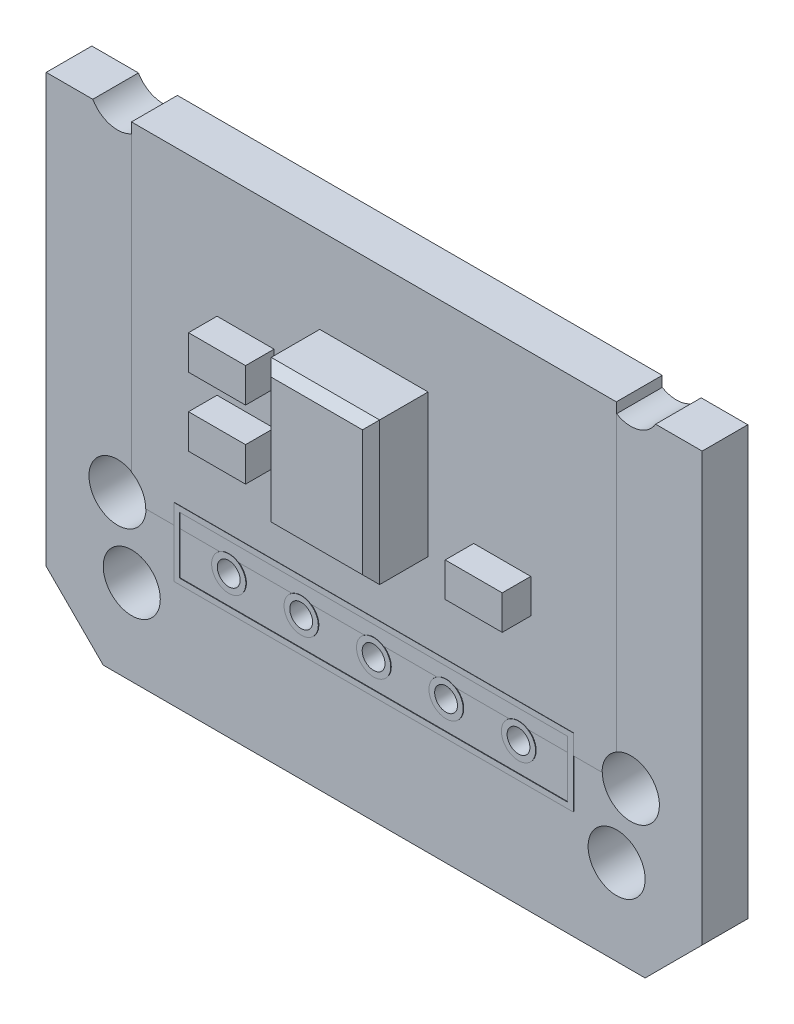
from build123d import *

# Parameters (mm, degrees)
SKETCH1_R           = 1
BOSS_EXTRUDE1_DEPTH = 1.6
SKETCH2_W           = 17
SKETCH2_H           = 12
BOSS_EXTRUDE2_DEPTH = 1.61
SKETCH3_W           = 14
SKETCH3_H           = 2.4
SKETCH3_W_2         = 13.6
SKETCH3_H_2         = 2
SKETCH3_R           = 0.6
SKETCH3_R_2         = 0.4
BOSS_EXTRUDE3_DEPTH = 1.62
SKETCH3_3_R         = 0.4
CUT_EXTRUDE1_DEPTH  = 2.62
BOSS_EXTRUDE4_START = 1.61
SKETCH4_W           = 3.8
SKETCH4_H           = 5
BOSS_EXTRUDE4_DEPTH = 2
BOSS_EXTRUDE5_START = 1.61
SKETCH5_W           = 2
SKETCH5_H           = 1.2
BOSS_EXTRUDE5_DEPTH = 1
CHAMFER1_SIZE       = 0.3
SKETCH6_R           = 1
SKETCH6_W           = 23
SKETCH6_H           = 6
CUT_EXTRUDE2_DEPTH  = 2


with BuildPart() as part:
    # Sketch1 → Boss-Extrude1 (new body)
    with BuildSketch(Plane.XY):
        Polygon((-11.5, 9.5), (-9.5, 11.5), (9.5, 11.5), (11.5, 9.5), (11.5, -9.5), (9.5, -11.5), (-9.5, -11.5), (-11.5, -9.5), align=None)
        with Locations((-9, 6)):
            Circle(SKETCH1_R, mode=Mode.SUBTRACT)
        with Locations((9, 6)):
            Circle(SKETCH1_R, mode=Mode.SUBTRACT)
        with Locations((-9, -6)):
            Circle(SKETCH1_R, mode=Mode.SUBTRACT)
        with Locations((9, -6)):
            Circle(SKETCH1_R, mode=Mode.SUBTRACT)
        with Locations((8.5, -8.5)):
            Circle(SKETCH1_R, mode=Mode.SUBTRACT)
        with Locations((-8.5, -8.5)):
            Circle(SKETCH1_R, mode=Mode.SUBTRACT)
    extrude(amount=BOSS_EXTRUDE1_DEPTH)

    # Sketch2 → Boss-Extrude2 (add)
    with BuildSketch(Plane.XY):
        Rectangle(SKETCH2_W, SKETCH2_H)
    extrude(amount=BOSS_EXTRUDE2_DEPTH)

    # Sketch3 → Boss-Extrude3 (add)
    with BuildSketch(Plane.XY):
        with Locations((0, -6.5)):
            Rectangle(SKETCH3_W, SKETCH3_H)
        with Locations((0, -6.5)):
            Rectangle(SKETCH3_W_2, SKETCH3_H_2, mode=Mode.SUBTRACT)
        with Locations(Location((-5.08, -6.5, 0), (0, 0, 123.557309762))):
            Circle(SKETCH3_R)
        with Locations((-5.08, -6.5)):
            Circle(SKETCH3_R_2, mode=Mode.SUBTRACT)
        with Locations(Location((-2.54, -6.5, 0), (0, 0, 123.557309762))):
            Circle(SKETCH3_R)
        with Locations((-2.54, -6.5)):
            Circle(SKETCH3_R_2, mode=Mode.SUBTRACT)
        with Locations(Location((0, -6.5, 0), (0, 0, 123.557309762))):
            Circle(SKETCH3_R)
        with Locations((0, -6.5)):
            Circle(SKETCH3_R_2, mode=Mode.SUBTRACT)
        with Locations(Location((5.08, -6.5, 0), (0, 0, 123.557309762))):
            Circle(SKETCH3_R)
        with Locations((5.08, -6.5)):
            Circle(SKETCH3_R_2, mode=Mode.SUBTRACT)
        with Locations(Location((2.54, -6.5, 0), (0, 0, 123.557309762))):
            Circle(SKETCH3_R)
        with Locations((2.54, -6.5)):
            Circle(SKETCH3_R_2, mode=Mode.SUBTRACT)
    extrude(amount=BOSS_EXTRUDE3_DEPTH)

    # Sketch3_3 → Cut-Extrude1 (cut)
    with BuildSketch(Plane.XY):
        with Locations((-5.08, -6.5)):
            Circle(SKETCH3_3_R)
        with Locations((-2.54, -6.5)):
            Circle(SKETCH3_3_R)
        with Locations((0, -6.5)):
            Circle(SKETCH3_3_R)
        with Locations((2.54, -6.5)):
            Circle(SKETCH3_3_R)
        with Locations((5.08, -6.5)):
            Circle(SKETCH3_3_R)
    extrude(amount=CUT_EXTRUDE1_DEPTH, mode=Mode.SUBTRACT)

    # Sketch4 → Boss-Extrude4 (add)
    with BuildSketch(Plane.XY.offset(BOSS_EXTRUDE4_START)):
        Rectangle(SKETCH4_W, SKETCH4_H)
    extrude(amount=BOSS_EXTRUDE4_DEPTH)

    # Sketch5 → Boss-Extrude5 (add)
    with BuildSketch(Plane.XY.offset(BOSS_EXTRUDE5_START)):
        with Locations((-4.500129294, -1.9)):
            Rectangle(SKETCH5_W, SKETCH5_H)
        with Locations((-4.5, 0.5)):
            Rectangle(SKETCH5_W, SKETCH5_H)
        with Locations((4.5, -1.9)):
            Rectangle(SKETCH5_W, SKETCH5_H)
    extrude(amount=BOSS_EXTRUDE5_DEPTH)

    # Chamfer1
    chamfer1_edges = [part.edges().sort_by_distance(p)[0] for p in [
        (1.9, 0, 3.61),
        (0, 2.5, 3.61),
        (-1.9, 0, 3.61),
        (0, -2.5, 3.61),
    ]]
    chamfer(chamfer1_edges, length=CHAMFER1_SIZE)

    # Sketch6 → Cut-Extrude2 (cut)
    with BuildSketch(Plane.XY):
        with Locations(Location((9, -6, 0), (0, 0, 180))):
            Circle(SKETCH6_R)
        with Locations((-9, -6)):
            Circle(SKETCH6_R)
        with Locations((0, 8.5)):
            Rectangle(SKETCH6_W, SKETCH6_H)
    extrude(amount=CUT_EXTRUDE2_DEPTH, mode=Mode.SUBTRACT)


solid = part.part
